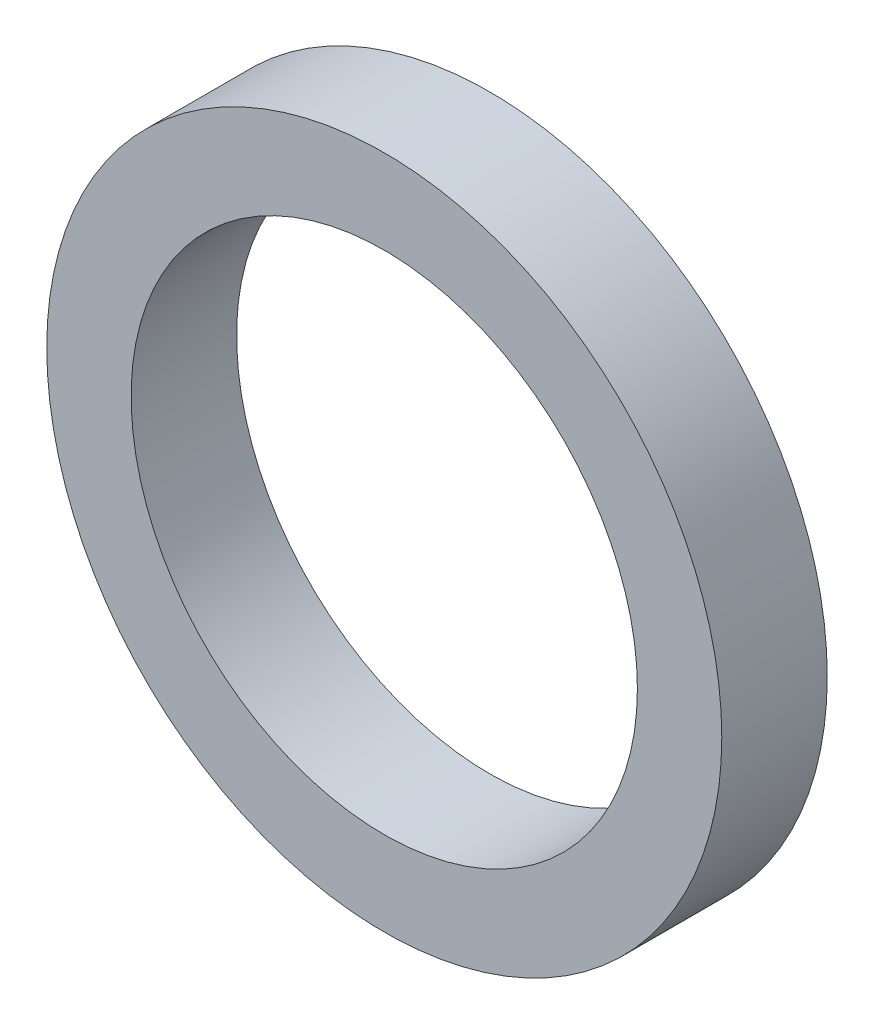
from build123d import *

# Parameters (mm, degrees)
SKETCH1_R           = 8
SKETCH1_R_2         = 6
BOSS_EXTRUDE1_DEPTH = 2.5


with BuildPart() as part:
    # Sketch1 → Boss-Extrude1 (new body)
    with BuildSketch(Plane.XY):
        Circle(SKETCH1_R)
        Circle(SKETCH1_R_2, mode=Mode.SUBTRACT)
    extrude(amount=BOSS_EXTRUDE1_DEPTH)


solid = part.part
